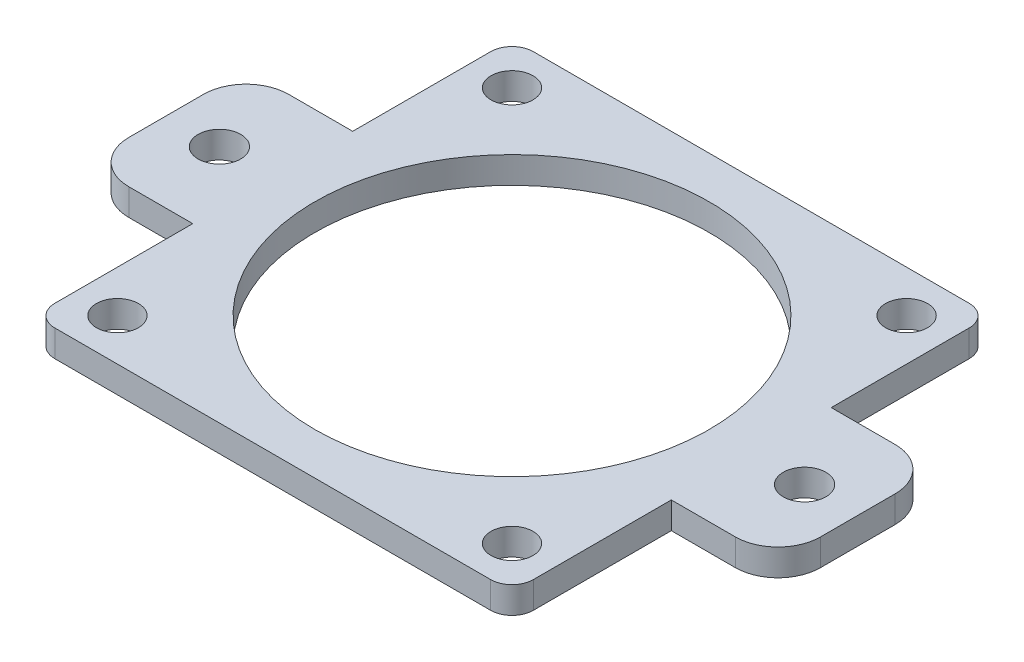
from build123d import *

# Parameters (mm, degrees)
SKETCH1_R           = 23.495
SKETCH1_R_2         = 2.499995
SKETCH1_R_3         = 2.54
BOSS_EXTRUDE1_DEPTH = 3.175


with BuildPart() as part:
    # Sketch1 → Boss-Extrude1 (new body)
    with BuildSketch(Plane(origin=(0, 0, 0), x_dir=(1, 0, 0), z_dir=(0, 1, 0))):
        with BuildLine():
            Line((-13.993314597, 28.4999938), (-25.9599938, 28.4999938))
            ThreePointArc((-25.9599938, 28.4999938), (-27.756045024, 27.756045024), (-28.4999938, 25.9599938))
            Line((-28.4999938, 25.9599938), (-28.4999938, 13.993314597))
            Line((-28.4999938, 13.993314597), (-28.4999938, 9.525))
            Line((-28.4999938, 9.525), (-36.1199938, 9.525))
            ThreePointArc((-36.1199938, 9.525), (-39.712096248, 8.037102448), (-41.1999938, 4.445))
            Line((-41.1999938, 4.445), (-41.1999938, -4.445))
            ThreePointArc((-41.1999938, -4.445), (-39.712096248, -8.037102448), (-36.1199938, -9.525))
            Line((-36.1199938, -9.525), (-28.4999938, -9.525))
            Line((-28.4999938, -9.525), (-28.4999938, -13.993314597))
            Line((-28.4999938, -13.993314597), (-28.4999938, -25.9599938))
            ThreePointArc((-28.4999938, -25.9599938), (-27.756045024, -27.756045024), (-25.9599938, -28.4999938))
            Line((-25.9599938, -28.4999938), (-13.993314597, -28.4999938))
            Line((-13.993314597, -28.4999938), (13.993314597, -28.4999938))
            Line((13.993314597, -28.4999938), (25.9599938, -28.4999938))
            ThreePointArc((25.9599938, -28.4999938), (27.756045024, -27.756045024), (28.4999938, -25.9599938))
            Line((28.4999938, -25.9599938), (28.4999938, -13.993314597))
            Line((28.4999938, -13.993314597), (28.4999938, -9.525))
            Line((28.4999938, -9.525), (36.1199938, -9.525))
            ThreePointArc((36.1199938, -9.525), (39.712096248, -8.037102448), (41.1999938, -4.445))
            Line((41.1999938, -4.445), (41.1999938, 4.445))
            ThreePointArc((41.1999938, 4.445), (39.712096248, 8.037102448), (36.1199938, 9.525))
            Line((36.1199938, 9.525), (28.4999938, 9.525))
            Line((28.4999938, 9.525), (28.4999938, 13.993314597))
            Line((28.4999938, 13.993314597), (28.4999938, 25.9599938))
            ThreePointArc((28.4999938, 25.9599938), (27.756045024, 27.756045024), (25.9599938, 28.4999938))
            Line((25.9599938, 28.4999938), (13.993314597, 28.4999938))
            Line((13.993314597, 28.4999938), (-13.993314597, 28.4999938))
        make_face()
        Circle(SKETCH1_R, mode=Mode.SUBTRACT)
        with Locations((-23.5000038, 23.5000038)):
            Circle(SKETCH1_R_2, mode=Mode.SUBTRACT)
        with Locations((23.5000038, 23.5000038)):
            Circle(SKETCH1_R_2, mode=Mode.SUBTRACT)
        with Locations((23.5000038, -23.5000038)):
            Circle(SKETCH1_R_2, mode=Mode.SUBTRACT)
        with Locations((-23.5000038, -23.5000038)):
            Circle(SKETCH1_R_2, mode=Mode.SUBTRACT)
        with Locations((-34.8499938, 0)):
            Circle(SKETCH1_R_3, mode=Mode.SUBTRACT)
        with Locations((34.8499938, 0)):
            Circle(SKETCH1_R_3, mode=Mode.SUBTRACT)
    extrude(amount=BOSS_EXTRUDE1_DEPTH)


solid = part.part
